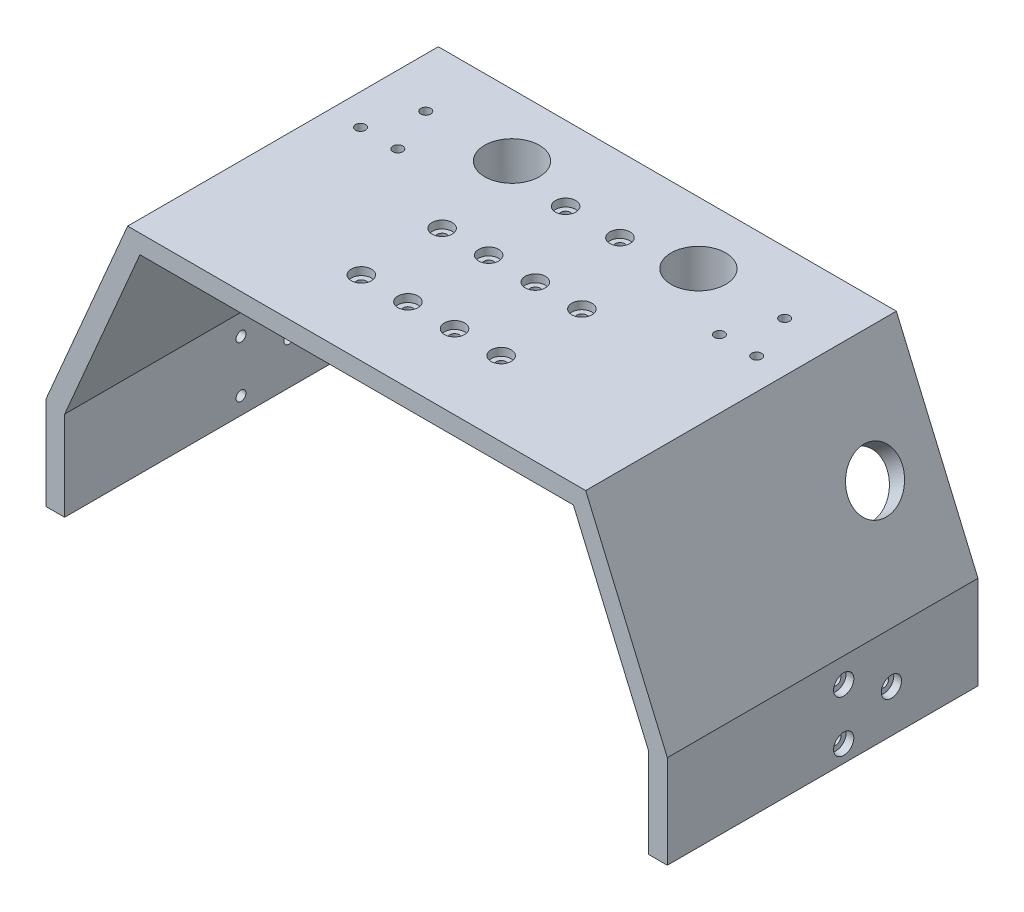
from build123d import *

# Parameters (mm, degrees)
SALIENTE_EXTRUIR1_DEPTH = 100
CORTAR_EXTRUIR1_REACH   = 170.346
CROQUIS3_R              = 8.8
CORTAR_EXTRUIR2_REACH   = 226.945
CROQUIS4_R              = 8.8
CORTAR_EXTRUIR3_DEPTH   = 0.5
CORTAR_EXTRUIR4_REACH   = 241.691
CROQUIS6_R              = 1.6
CROQUIS7_R              = 3.25
CORTAR_EXTRUIR5_DEPTH   = 2.5
CROQUIS8_W              = 75
CROQUIS8_H              = 12
CROQUIS8_W_2            = 35
CORTAR_EXTRUIR6_DEPTH   = 2.5
CORTAR_EXTRUIR7_REACH   = 168.473
CROQUIS9_R              = 1.6
CROQUIS10_R             = 3.25
CORTAR_EXTRUIR8_DEPTH   = 2.5
CROQUIS11_R             = 10.3
CROQUIS11_R_2           = 8.8
SALIENTE_EXTRUIR2_DEPTH = 10
SALIENTE_EXTRUIR3_REACH = 201.802
CROQUIS12_R             = 10.3
CROQUIS12_R_2           = 8.8
CORTAR_EXTRUIR9_REACH   = 167.168
CROQUIS13_R             = 1.6


with BuildPart() as part:
    # Croquis1 → Saliente-Extruir1 (new body)
    with BuildSketch(Plane.XY):
        Polygon((-100, 25), (-100, -5), (-94, -5), (-94, 23.768453788), (-69.761533754, 80.324875029), (69.761533754, 80.324875029), (94, 23.768453788), (94, -5), (100, -5), (100, 25), (73.717910702, 86.324875029), (-73.717910702, 86.324875029), align=None)
    extrude(amount=SALIENTE_EXTRUIR1_DEPTH)

    # Croquis3 → Cortar-Extruir1 (cut, up to next)
    with BuildSketch(Plane(origin=(0, 86.324875029, 0), x_dir=(1, 0, 0), z_dir=(0, 1, 0)), mode=Mode.PRIVATE) as cortar_extruir1_sk1:
        with Locations(Location((-30, -20, 0), (0, 0, 270))):
            Circle(CROQUIS3_R)
    cortar_extruir1_tool1 = extrude(cortar_extruir1_sk1.sketch, amount=-CORTAR_EXTRUIR1_REACH, mode=Mode.PRIVATE) & part.part
    # Croquis3 → Cortar-Extruir1 (cut, up to next)
    with BuildSketch(Plane(origin=(0, 86.324875029, 0), x_dir=(1, 0, 0), z_dir=(0, 1, 0)), mode=Mode.PRIVATE) as cortar_extruir1_sk2:
        with Locations(Location((30, -20, 0), (0, 0, 270))):
            Circle(CROQUIS3_R)
    cortar_extruir1_tool2 = extrude(cortar_extruir1_sk2.sketch, amount=-CORTAR_EXTRUIR1_REACH, mode=Mode.PRIVATE) & part.part
    add(cortar_extruir1_tool1.solids().sort_by_distance((-30, 86.324875, 20))[0], mode=Mode.SUBTRACT)
    add(cortar_extruir1_tool2.solids().sort_by_distance((30, 86.324875, 20))[0], mode=Mode.SUBTRACT)

    # Cortar-Extruir2: up to this plane
    cortar_extruir2_end = Plane(origin=(-94, 23.768453788, 100), z_dir=(-0.9191450300180581, 0.3939192985791672, 0))
    # Croquis4 → Cortar-Extruir2 (cut, up to the surface)
    with BuildSketch(Plane(origin=(-87.479517168, 68.836107355, 0), x_dir=(0, 0, -1), z_dir=(-0.7858721058939679, 0.6183890629512945, 0)), mode=Mode.PRIVATE) as cortar_extruir2_sk1:
        with Locations(Location((-20, 9.96907102, 0), (0, 0, 270))):
            Circle(CROQUIS4_R)
    cortar_extruir2_tool1 = split(extrude(cortar_extruir2_sk1.sketch, amount=-CORTAR_EXTRUIR2_REACH, mode=Mode.PRIVATE), bisect_by=cortar_extruir2_end, keep=Keep.BOTH, mode=Mode.PRIVATE)
    cortar_extruir2 = cortar_extruir2_tool1.solids().sort_by_distance((-93.644282, 61.001693, 20))[0]
    add(cortar_extruir2, mode=Mode.SUBTRACT)

    # Simetría1: Cortar-Extruir2 across plane
    add(cortar_extruir2.mirror(Plane(origin=(0, 0, 0), x_dir=(0, 0, 1), z_dir=(1, 0, 0))), mode=Mode.SUBTRACT)

    # Croquis5 → Cortar-Extruir3 (cut)
    with BuildSketch(Plane.XZ.offset(-80.324875029)):
        with BuildLine():
            Line((14.875, 0), (15.175, 0))
            Line((15.175, 0), (15.175, 2.3))
            Line((15.175, 2.3), (3.784177586, 2.3))
            ThreePointArc((3.784177586, 2.3), (0, 3.1), (-3.784177586, 2.3))
            Line((-3.784177586, 2.3), (-15.175, 2.3))
            Line((-15.175, 2.3), (-15.175, 0))
            Line((-15.175, 0), (-14.875, 0))
            Line((-14.875, 0), (-14.875, 2))
            Line((-14.875, 2), (-3.720215048, 2))
            ThreePointArc((-3.720215048, 2), (0, 2.8), (3.720215048, 2))
            Line((3.720215048, 2), (14.875, 2))
            Line((14.875, 2), (14.875, 0))
        make_face()
        with BuildLine():
            Line((3.261901286, 0), (14.875, 0))
            Line((14.875, 0), (14.875, 2))
            Line((14.875, 2), (3.720215048, 2))
            ThreePointArc((3.720215048, 2), (0, 2.8), (-3.720215048, 2))
            Line((-3.720215048, 2), (-14.875, 2))
            Line((-14.875, 2), (-14.875, 0))
            Line((-14.875, 0), (-3.261901286, 0))
            ThreePointArc((-3.261901286, 0), (0, 0.8), (3.261901286, 0))
        make_face()
        with BuildLine():
            Line((-3.261901286, 0), (3.261901286, 0))
            ThreePointArc((3.261901286, 0), (0, 0.8), (-3.261901286, 0))
        make_face()
    extrude(amount=-CORTAR_EXTRUIR3_DEPTH, mode=Mode.SUBTRACT)

    # Croquis6 → Cortar-Extruir4 (cut, up to next)
    with BuildSketch(Plane.ZY.offset(100), mode=Mode.PRIVATE) as cortar_extruir4_sk1:
        with Locations(Location((43.227046774, 0.497681725, 0), (0, 0, 270))):
            Circle(CROQUIS6_R)
    cortar_extruir4_tool1 = extrude(cortar_extruir4_sk1.sketch, amount=-CORTAR_EXTRUIR4_REACH, mode=Mode.PRIVATE) & part.part
    # Croquis6 → Cortar-Extruir4 (cut, up to next)
    with BuildSketch(Plane.ZY.offset(100), mode=Mode.PRIVATE) as cortar_extruir4_sk2:
        with Locations(Location((27.863523387, 8.768453788, 0), (0, 0, 270))):
            Circle(CROQUIS6_R)
    cortar_extruir4_tool2 = extrude(cortar_extruir4_sk2.sketch, amount=-CORTAR_EXTRUIR4_REACH, mode=Mode.PRIVATE) & part.part
    # Croquis6 → Cortar-Extruir4 (cut, up to next)
    with BuildSketch(Plane.ZY.offset(100), mode=Mode.PRIVATE) as cortar_extruir4_sk3:
        with Locations(Location((43.227046774, 17.039225851, 0), (0, 0, 270))):
            Circle(CROQUIS6_R)
    cortar_extruir4_tool3 = extrude(cortar_extruir4_sk3.sketch, amount=-CORTAR_EXTRUIR4_REACH, mode=Mode.PRIVATE) & part.part
    cortar_extruir4_1 = cortar_extruir4_tool1.solids().sort_by_distance((-100, 0.497682, 43.227047))[0]
    add(cortar_extruir4_1, mode=Mode.SUBTRACT)
    cortar_extruir4_2 = cortar_extruir4_tool2.solids().sort_by_distance((-100, 8.768454, 27.863523))[0]
    add(cortar_extruir4_2, mode=Mode.SUBTRACT)
    cortar_extruir4_3 = cortar_extruir4_tool3.solids().sort_by_distance((-100, 17.039226, 43.227047))[0]
    add(cortar_extruir4_3, mode=Mode.SUBTRACT)
    cortar_extruir4 = cortar_extruir4_1 + cortar_extruir4_2 + cortar_extruir4_3  # Cortar-Extruir4 as one shape, for the pattern or mirror that repeats it

    # Croquis7 → Cortar-Extruir5 (cut)
    with BuildSketch(Plane.ZY.offset(100)):
        with Locations(Location((27.863523387, 8.768453788, 0), (0, 0, 270))):
            Circle(CROQUIS7_R)
        with Locations(Location((43.227046774, 0.497681725, 0), (0, 0, 270))):
            Circle(CROQUIS7_R)
        with Locations(Location((43.227046774, 17.039225851, 0), (0, 0, 270))):
            Circle(CROQUIS7_R)
    cortar_extruir5 = extrude(amount=-CORTAR_EXTRUIR5_DEPTH, mode=Mode.SUBTRACT)

    # Simetría2: Cortar-Extruir4, Cortar-Extruir5 across plane
    add(cortar_extruir4.mirror(Plane(origin=(0, 0, 0), x_dir=(0, 0, 1), z_dir=(1, 0, 0))), mode=Mode.SUBTRACT)
    add(cortar_extruir5.mirror(Plane(origin=(0, 0, 0), x_dir=(0, 0, 1), z_dir=(1, 0, 0))), mode=Mode.SUBTRACT)

    # Croquis8 → Cortar-Extruir6 (cut)
    with BuildSketch(Plane.XZ.offset(-80.324875029)):
        with Locations((0, 76)):
            Rectangle(CROQUIS8_W, CROQUIS8_H)
        with Locations((0, 50)):
            Rectangle(CROQUIS8_W, CROQUIS8_H)
        with Locations((0, 24)):
            Rectangle(CROQUIS8_W_2, CROQUIS8_H)
    extrude(amount=-CORTAR_EXTRUIR6_DEPTH, mode=Mode.SUBTRACT)

    # Croquis9 → Cortar-Extruir7 (cut, up to next)
    with BuildSketch(Plane.XZ.offset(-82.824875029), mode=Mode.PRIVATE) as cortar_extruir7_sk1:
        with Locations(Location((-22.5, 76, 0), (0, 0, 270))):
            Circle(CROQUIS9_R)
    cortar_extruir7_tool1 = extrude(cortar_extruir7_sk1.sketch, amount=-CORTAR_EXTRUIR7_REACH, mode=Mode.PRIVATE) & part.part
    # Croquis9 → Cortar-Extruir7 (cut, up to next)
    with BuildSketch(Plane.XZ.offset(-82.824875029), mode=Mode.PRIVATE) as cortar_extruir7_sk2:
        with Locations(Location((-7.5, 76, 0), (0, 0, 270))):
            Circle(CROQUIS9_R)
    cortar_extruir7_tool2 = extrude(cortar_extruir7_sk2.sketch, amount=-CORTAR_EXTRUIR7_REACH, mode=Mode.PRIVATE) & part.part
    # Croquis9 → Cortar-Extruir7 (cut, up to next)
    with BuildSketch(Plane.XZ.offset(-82.824875029), mode=Mode.PRIVATE) as cortar_extruir7_sk3:
        with Locations(Location((7.5, 76, 0), (0, 0, 270))):
            Circle(CROQUIS9_R)
    cortar_extruir7_tool3 = extrude(cortar_extruir7_sk3.sketch, amount=-CORTAR_EXTRUIR7_REACH, mode=Mode.PRIVATE) & part.part
    # Croquis9 → Cortar-Extruir7 (cut, up to next)
    with BuildSketch(Plane.XZ.offset(-82.824875029), mode=Mode.PRIVATE) as cortar_extruir7_sk4:
        with Locations(Location((22.5, 76, 0), (0, 0, 270))):
            Circle(CROQUIS9_R)
    cortar_extruir7_tool4 = extrude(cortar_extruir7_sk4.sketch, amount=-CORTAR_EXTRUIR7_REACH, mode=Mode.PRIVATE) & part.part
    # Croquis9 → Cortar-Extruir7 (cut, up to next)
    with BuildSketch(Plane.XZ.offset(-82.824875029), mode=Mode.PRIVATE) as cortar_extruir7_sk5:
        with Locations(Location((-22.5, 50, 0), (0, 0, 270))):
            Circle(CROQUIS9_R)
    cortar_extruir7_tool5 = extrude(cortar_extruir7_sk5.sketch, amount=-CORTAR_EXTRUIR7_REACH, mode=Mode.PRIVATE) & part.part
    # Croquis9 → Cortar-Extruir7 (cut, up to next)
    with BuildSketch(Plane.XZ.offset(-82.824875029), mode=Mode.PRIVATE) as cortar_extruir7_sk6:
        with Locations(Location((-7.5, 50, 0), (0, 0, 270))):
            Circle(CROQUIS9_R)
    cortar_extruir7_tool6 = extrude(cortar_extruir7_sk6.sketch, amount=-CORTAR_EXTRUIR7_REACH, mode=Mode.PRIVATE) & part.part
    # Croquis9 → Cortar-Extruir7 (cut, up to next)
    with BuildSketch(Plane.XZ.offset(-82.824875029), mode=Mode.PRIVATE) as cortar_extruir7_sk7:
        with Locations(Location((7.5, 50, 0), (0, 0, 270))):
            Circle(CROQUIS9_R)
    cortar_extruir7_tool7 = extrude(cortar_extruir7_sk7.sketch, amount=-CORTAR_EXTRUIR7_REACH, mode=Mode.PRIVATE) & part.part
    # Croquis9 → Cortar-Extruir7 (cut, up to next)
    with BuildSketch(Plane.XZ.offset(-82.824875029), mode=Mode.PRIVATE) as cortar_extruir7_sk8:
        with Locations(Location((22.5, 50, 0), (0, 0, 270))):
            Circle(CROQUIS9_R)
    cortar_extruir7_tool8 = extrude(cortar_extruir7_sk8.sketch, amount=-CORTAR_EXTRUIR7_REACH, mode=Mode.PRIVATE) & part.part
    # Croquis9 → Cortar-Extruir7 (cut, up to next)
    with BuildSketch(Plane.XZ.offset(-82.824875029), mode=Mode.PRIVATE) as cortar_extruir7_sk9:
        with Locations(Location((-8.75, 24, 0), (0, 0, 270))):
            Circle(CROQUIS9_R)
    cortar_extruir7_tool9 = extrude(cortar_extruir7_sk9.sketch, amount=-CORTAR_EXTRUIR7_REACH, mode=Mode.PRIVATE) & part.part
    # Croquis9 → Cortar-Extruir7 (cut, up to next)
    with BuildSketch(Plane.XZ.offset(-82.824875029), mode=Mode.PRIVATE) as cortar_extruir7_sk10:
        with Locations(Location((8.75, 24, 0), (0, 0, 270))):
            Circle(CROQUIS9_R)
    cortar_extruir7_tool10 = extrude(cortar_extruir7_sk10.sketch, amount=-CORTAR_EXTRUIR7_REACH, mode=Mode.PRIVATE) & part.part
    add(cortar_extruir7_tool1.solids().sort_by_distance((-22.5, 82.824875, 76))[0], mode=Mode.SUBTRACT)
    add(cortar_extruir7_tool2.solids().sort_by_distance((-7.5, 82.824875, 76))[0], mode=Mode.SUBTRACT)
    add(cortar_extruir7_tool3.solids().sort_by_distance((7.5, 82.824875, 76))[0], mode=Mode.SUBTRACT)
    add(cortar_extruir7_tool4.solids().sort_by_distance((22.5, 82.824875, 76))[0], mode=Mode.SUBTRACT)
    add(cortar_extruir7_tool5.solids().sort_by_distance((-22.5, 82.824875, 50))[0], mode=Mode.SUBTRACT)
    add(cortar_extruir7_tool6.solids().sort_by_distance((-7.5, 82.824875, 50))[0], mode=Mode.SUBTRACT)
    add(cortar_extruir7_tool7.solids().sort_by_distance((7.5, 82.824875, 50))[0], mode=Mode.SUBTRACT)
    add(cortar_extruir7_tool8.solids().sort_by_distance((22.5, 82.824875, 50))[0], mode=Mode.SUBTRACT)
    add(cortar_extruir7_tool9.solids().sort_by_distance((-8.75, 82.824875, 24))[0], mode=Mode.SUBTRACT)
    add(cortar_extruir7_tool10.solids().sort_by_distance((8.75, 82.824875, 24))[0], mode=Mode.SUBTRACT)

    # Croquis10 → Cortar-Extruir8 (cut)
    with BuildSketch(Plane(origin=(0, 86.324875029, 0), x_dir=(1, 0, 0), z_dir=(0, 1, 0))):
        with Locations(Location((-22.5, -50, 0), (0, 0, 270))):
            Circle(CROQUIS10_R)
        with Locations(Location((-7.5, -50, 0), (0, 0, 270))):
            Circle(CROQUIS10_R)
        with Locations(Location((7.5, -50, 0), (0, 0, 270))):
            Circle(CROQUIS10_R)
        with Locations(Location((22.5, -50, 0), (0, 0, 270))):
            Circle(CROQUIS10_R)
        with Locations(Location((8.75, -24, 0), (0, 0, 270))):
            Circle(CROQUIS10_R)
        with Locations(Location((-8.75, -24, 0), (0, 0, 270))):
            Circle(CROQUIS10_R)
        with Locations(Location((22.5, -76, 0), (0, 0, 270))):
            Circle(CROQUIS10_R)
        with Locations(Location((7.5, -76, 0), (0, 0, 270))):
            Circle(CROQUIS10_R)
        with Locations(Location((-7.5, -76, 0), (0, 0, 270))):
            Circle(CROQUIS10_R)
        with Locations(Location((-22.5, -76, 0), (0, 0, 270))):
            Circle(CROQUIS10_R)
    extrude(amount=-CORTAR_EXTRUIR8_DEPTH, mode=Mode.SUBTRACT)

    # Croquis11 → Saliente-Extruir2 (add)
    with BuildSketch(Plane.XZ.offset(-80.324875029)):
        with Locations(Location((-30, 20, 0), (0, 0, 90))):
            Circle(CROQUIS11_R)
        with Locations(Location((-30, 20, 0), (0, 0, 90))):
            Circle(CROQUIS11_R_2, mode=Mode.SUBTRACT)
        with Locations(Location((30, 20, 0), (0, 0, 90))):
            Circle(CROQUIS11_R)
        with Locations(Location((30, 20, 0), (0, 0, 90))):
            Circle(CROQUIS11_R_2, mode=Mode.SUBTRACT)
    extrude(amount=SALIENTE_EXTRUIR2_DEPTH)

    # Saliente-Extruir3: up to this plane
    saliente_extruir3_end = Plane(origin=(-94, 23.768453788, 100), z_dir=(-0.9191450300180581, 0.3939192985791672, 0))
    # Croquis12 → Saliente-Extruir3 (add, up to the surface)
    with BuildSketch(Plane(origin=(-63.903353991, 50.284435467, 0), x_dir=(0, 0, -1), z_dir=(-0.7858721058939679, 0.6183890629512945, 0)), mode=Mode.PRIVATE) as saliente_extruir3_sk1:
        with Locations(Location((-20, 9.96907102, 0), (0, 0, 90))):
            Circle(CROQUIS12_R)
        with Locations(Location((-20, 9.96907102, 0), (0, 0, 90))):
            Circle(CROQUIS12_R_2, mode=Mode.SUBTRACT)
    saliente_extruir3_tool1 = split(extrude(saliente_extruir3_sk1.sketch, amount=SALIENTE_EXTRUIR3_REACH, mode=Mode.PRIVATE), bisect_by=saliente_extruir3_end, keep=Keep.BOTH, mode=Mode.PRIVATE)
    add(saliente_extruir3_tool1.solids().sort_by_distance((-63.878865, 50.315557, 20))[0])

    # Croquis13 → Cortar-Extruir9 (cut, up to next)
    with BuildSketch(Plane.XZ.offset(-80.324875029), mode=Mode.PRIVATE) as cortar_extruir9_sk1:
        with Locations(Location((57.761533754, 20, 0), (0, 0, 270))):
            Circle(CROQUIS13_R)
    cortar_extruir9_tool1 = extrude(cortar_extruir9_sk1.sketch, amount=-CORTAR_EXTRUIR9_REACH, mode=Mode.PRIVATE) & part.part
    # Croquis13 → Cortar-Extruir9 (cut, up to next)
    with BuildSketch(Plane.XZ.offset(-80.324875029), mode=Mode.PRIVATE) as cortar_extruir9_sk2:
        with Locations(Location((51.761533754, 35, 0), (0, 0, 270))):
            Circle(CROQUIS13_R)
    cortar_extruir9_tool2 = extrude(cortar_extruir9_sk2.sketch, amount=-CORTAR_EXTRUIR9_REACH, mode=Mode.PRIVATE) & part.part
    # Croquis13 → Cortar-Extruir9 (cut, up to next)
    with BuildSketch(Plane.XZ.offset(-80.324875029), mode=Mode.PRIVATE) as cortar_extruir9_sk3:
        with Locations(Location((63.761533754, 35, 0), (0, 0, 270))):
            Circle(CROQUIS13_R)
    cortar_extruir9_tool3 = extrude(cortar_extruir9_sk3.sketch, amount=-CORTAR_EXTRUIR9_REACH, mode=Mode.PRIVATE) & part.part
    # Croquis13 → Cortar-Extruir9 (cut, up to next)
    with BuildSketch(Plane.XZ.offset(-80.324875029), mode=Mode.PRIVATE) as cortar_extruir9_sk4:
        with Locations(Location((-57.761533754, 20, 0), (0, 0, 270))):
            Circle(CROQUIS13_R)
    cortar_extruir9_tool4 = extrude(cortar_extruir9_sk4.sketch, amount=-CORTAR_EXTRUIR9_REACH, mode=Mode.PRIVATE) & part.part
    # Croquis13 → Cortar-Extruir9 (cut, up to next)
    with BuildSketch(Plane.XZ.offset(-80.324875029), mode=Mode.PRIVATE) as cortar_extruir9_sk5:
        with Locations(Location((-63.761533754, 35, 0), (0, 0, 270))):
            Circle(CROQUIS13_R)
    cortar_extruir9_tool5 = extrude(cortar_extruir9_sk5.sketch, amount=-CORTAR_EXTRUIR9_REACH, mode=Mode.PRIVATE) & part.part
    # Croquis13 → Cortar-Extruir9 (cut, up to next)
    with BuildSketch(Plane.XZ.offset(-80.324875029), mode=Mode.PRIVATE) as cortar_extruir9_sk6:
        with Locations(Location((-51.761533754, 35, 0), (0, 0, 270))):
            Circle(CROQUIS13_R)
    cortar_extruir9_tool6 = extrude(cortar_extruir9_sk6.sketch, amount=-CORTAR_EXTRUIR9_REACH, mode=Mode.PRIVATE) & part.part
    add(cortar_extruir9_tool1.solids().sort_by_distance((57.761534, 80.324875, 20))[0], mode=Mode.SUBTRACT)
    add(cortar_extruir9_tool2.solids().sort_by_distance((51.761534, 80.324875, 35))[0], mode=Mode.SUBTRACT)
    add(cortar_extruir9_tool3.solids().sort_by_distance((63.761534, 80.324875, 35))[0], mode=Mode.SUBTRACT)
    add(cortar_extruir9_tool4.solids().sort_by_distance((-57.761534, 80.324875, 20))[0], mode=Mode.SUBTRACT)
    add(cortar_extruir9_tool5.solids().sort_by_distance((-63.761534, 80.324875, 35))[0], mode=Mode.SUBTRACT)
    add(cortar_extruir9_tool6.solids().sort_by_distance((-51.761534, 80.324875, 35))[0], mode=Mode.SUBTRACT)


solid = part.part
